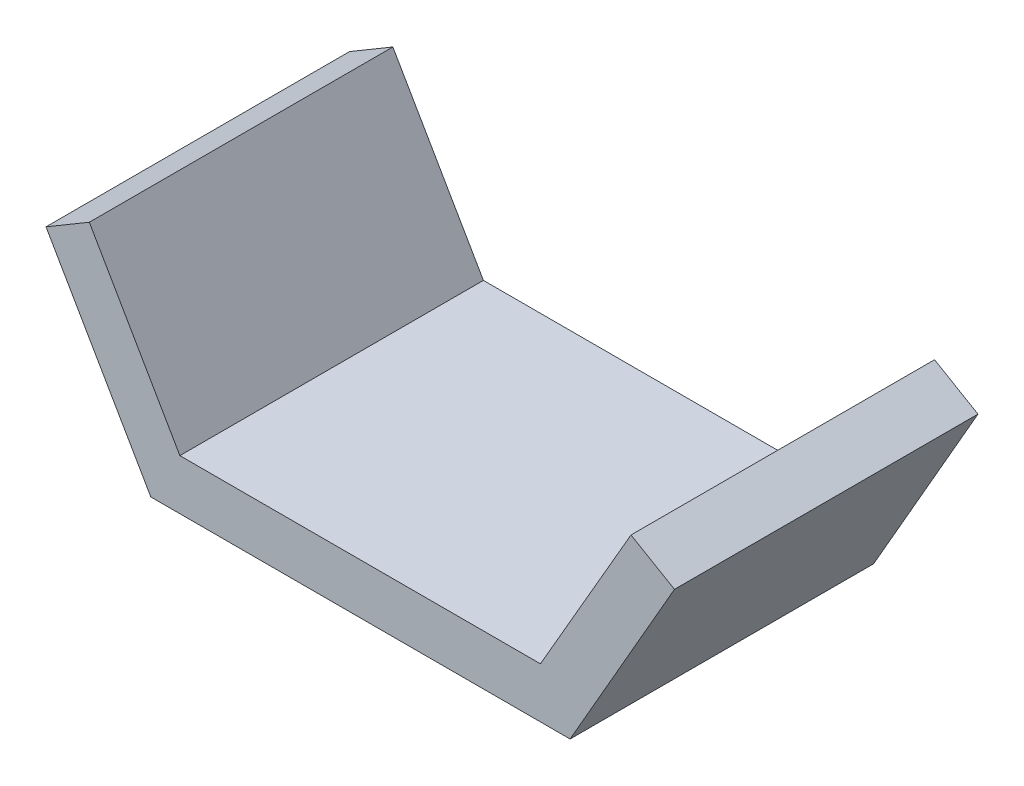
from build123d import *

# Parameters (mm, degrees)
SALIENTE_EXTRUIR1_DEPTH = 1810


with BuildPart() as part:
    # Croquis1 → Saliente-Extruir1 (new body)
    with BuildSketch(Plane.XY):
        Polygon((-113.345721284, -408.189274437), (2036.654278716, -408.189274437), (2576.654278716, 527.11816165), (2835.751995862, 375.895236901), (2213.44919796, -708.189274437), (-286.55080204, -708.189274437), (-911.55080204, 374.342480294), (-653.345721284, 527.11816165), align=None)
    extrude(amount=SALIENTE_EXTRUIR1_DEPTH)


solid = part.part
